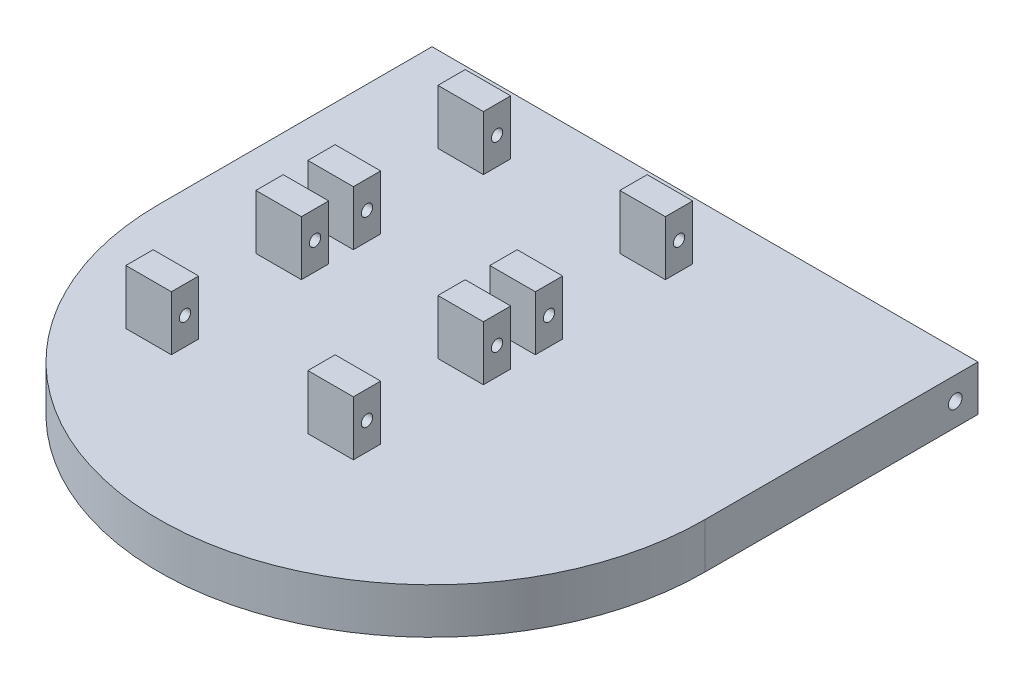
from build123d import *

# Parameters (mm, degrees)
BOSS_EXTRUDE1_DEPTH     = 10
SKETCH2_R               = 1.5
CUT_EXTRUDE1_DEPTH      = 1
CUT_EXTRUDE1_DEPTH_BACK = 121
BOSS_EXTRUDE2_START     = -20
SKETCH5_W               = 6
SKETCH5_H               = 12
SKETCH5_R               = 1.25
BOSS_EXTRUDE2_DEPTH     = 10
LPATTERN1_COUNT         = 2
LPATTERN1_PITCH         = 40
LPATTERN1_COUNT_DIR2    = 2
LPATTERN1_PITCH_DIR2    = 40
BOSS_EXTRUDE4_DEPTH     = 18
CHAMFER1_SIZE           = 15


with BuildPart() as part:
    # Sketch1 → Boss-Extrude1 (new body)
    with BuildSketch(Plane(origin=(0, 0, 0), x_dir=(1, 0, 0), z_dir=(0, 1, 0))):
        with BuildLine():
            Line((-60, 0), (-60, 60))
            Line((-60, 60), (60, 60))
            Line((60, 60), (60, 0))
            ThreePointArc((60, 0), (0, -60), (-60, 0))
        make_face()
    extrude(amount=BOSS_EXTRUDE1_DEPTH)

    # Sketch2 → Cut-Extrude1 (cut, two sides)
    with BuildSketch(Plane.ZY.offset(60)) as cut_extrude1_sk:
        with Locations((-55, 5)):
            Circle(SKETCH2_R)
    extrude(amount=CUT_EXTRUDE1_DEPTH, mode=Mode.SUBTRACT)
    extrude(cut_extrude1_sk.sketch, amount=-CUT_EXTRUDE1_DEPTH_BACK, mode=Mode.SUBTRACT)

    # Sketch5 → Boss-Extrude2 (add)
    with BuildSketch(Plane.ZY.offset(60).offset(BOSS_EXTRUDE2_START)):
        with Locations((-44.29, 16)):
            Rectangle(SKETCH5_W, SKETCH5_H)
        with Locations((-44.29, 16)):
            Circle(SKETCH5_R, mode=Mode.SUBTRACT)
        with Locations((-15.71, 16)):
            Rectangle(SKETCH5_W, SKETCH5_H)
        with Locations((-15.71, 16)):
            Circle(SKETCH5_R, mode=Mode.SUBTRACT)
    boss_extrude2 = extrude(amount=-BOSS_EXTRUDE2_DEPTH)

    # LPattern1: Boss-Extrude2 2 × 2
    with Locations(*[(i * LPATTERN1_PITCH, 0, j * LPATTERN1_PITCH_DIR2) for i in range(LPATTERN1_COUNT) for j in range(LPATTERN1_COUNT_DIR2) if (i, j) != (0, 0)]):
        add(boss_extrude2)

    # Sketch9 → Boss-Extrude4 (add)
    with BuildSketch(Plane.XZ):
        Polygon((-53.548293043, -27.012784213), (-43.443719976, -21.178906233), (-41.83944897, -23.957585125), (-51.944022036, -29.791463105), align=None)
        Polygon((-9.957561883, -1.845663844), (0.147011183, 3.988214136), (1.75128219, 1.209535244), (-8.353290877, -4.624342736), align=None)
    extrude(amount=BOSS_EXTRUDE4_DEPTH)

    # Chamfer1
    chamfer1_edges = [part.edges().sort_by_distance(p)[0] for p in [
        (-46.891735503, 0, -26.874524115),
        (-3.301004344, 0, -1.707403746),
    ]]
    chamfer(chamfer1_edges, length=CHAMFER1_SIZE)


solid = part.part
